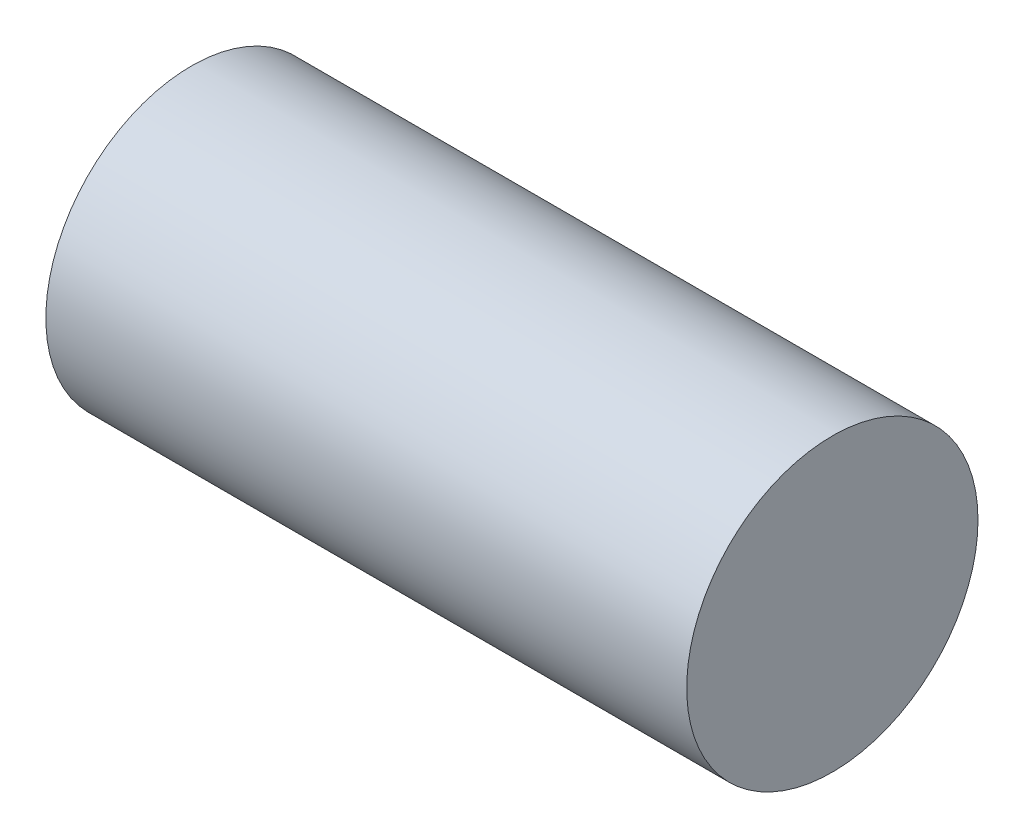
from build123d import *

# Parameters (mm, degrees)
SKETCH1_R           = 1.27
BOSS_EXTRUDE1_DEPTH = 5.588


with BuildPart() as part:
    # Sketch1 → Boss-Extrude1 (new body)
    with BuildSketch(Plane(origin=(0, 0, 0), x_dir=(0, 0, -1), z_dir=(1, 0, 0))):
        Circle(SKETCH1_R)
    extrude(amount=BOSS_EXTRUDE1_DEPTH)


solid = part.part
